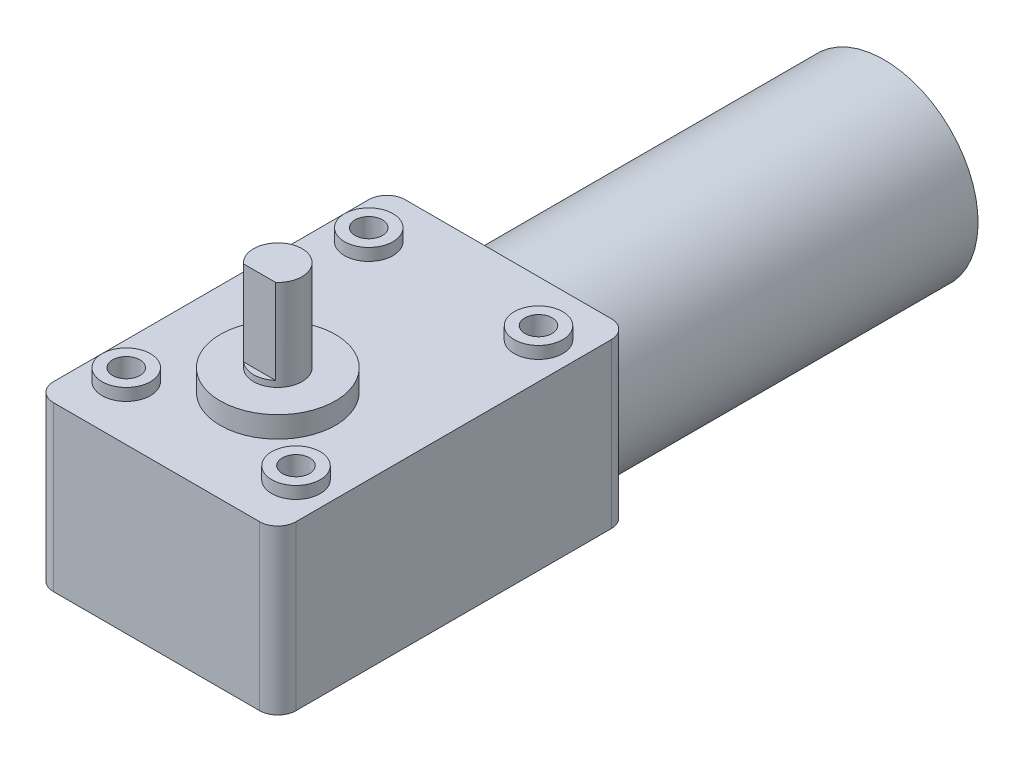
from build123d import *

# Parameters (mm, degrees)
BOSS_EXTRUDE2_DEPTH      = 27
SKETCH2_R                = 4
BOSS_EXTRUDE3_DEPTH      = 2
SKETCH3_R                = 9.5
BOSS_EXTRUDE4_DEPTH      = 3.5
SKETCH4_R                = 4
BOSS_EXTRUDE5_DEPTH      = 1
BOSS_EXTRUDE6_DEPTH      = 14
M4_CLEARANCE_HOLE1_D     = 4.5
M4_CLEARANCE_HOLE1_DEPTH = 9
M4_CLEARANCE_HOLE1_TIP   = 1.351936393
SKETCH8_R                = 15.5
BOSS_EXTRUDE7_DEPTH      = 62
SKETCH9_R                = 7.5
BOSS_EXTRUDE8_DEPTH      = 2


with BuildPart() as part:
    # Sketch1 → Boss-Extrude2 (new body)
    with BuildSketch(Plane(origin=(0, 0, 0), x_dir=(0, 0, -1), z_dir=(0, 1, 0))):
        with BuildLine():
            Line((3, 0), (55, 0))
            ThreePointArc((55, 0), (57.121320344, 0.878679656), (58, 3))
            Line((58, 3), (58, 37))
            ThreePointArc((58, 37), (57.121320344, 39.121320344), (55, 40))
            Line((55, 40), (3, 40))
            ThreePointArc((3, 40), (0.878679656, 39.121320344), (0, 37))
            Line((0, 37), (0, 3))
            ThreePointArc((0, 3), (0.878679656, 0.878679656), (3, 0))
        make_face()
    extrude(amount=BOSS_EXTRUDE2_DEPTH)

    # Sketch2 → Boss-Extrude3 (add)
    with BuildSketch(Plane(origin=(0, 27, 0), x_dir=(1, 0, 0), z_dir=(0, 1, 0))):
        with Locations((-34, 9)):
            Circle(SKETCH2_R)
        with Locations((-6, 9)):
            Circle(SKETCH2_R)
        with Locations((-6, 49)):
            Circle(SKETCH2_R)
        with Locations((-34, 49)):
            Circle(SKETCH2_R)
    extrude(amount=BOSS_EXTRUDE3_DEPTH)

    # Sketch3 → Boss-Extrude4 (add)
    with BuildSketch(Plane(origin=(0, 27, 0), x_dir=(1, 0, 0), z_dir=(0, 1, 0))):
        with Locations((-20, 20)):
            Circle(SKETCH3_R)
    extrude(amount=BOSS_EXTRUDE4_DEPTH)

    # Sketch4 → Boss-Extrude5 (add)
    with BuildSketch(Plane(origin=(0, 30.5, 0), x_dir=(1, 0, 0), z_dir=(0, 1, 0))):
        with Locations((-20, 20)):
            Circle(SKETCH4_R)
    extrude(amount=BOSS_EXTRUDE5_DEPTH)

    # Sketch5 → Boss-Extrude6 (add)
    with BuildSketch(Plane(origin=(0, 31.5, 0), x_dir=(1, 0, 0), z_dir=(0, 1, 0))):
        with BuildLine():
            Line((-22.645751311, 17), (-17.354248689, 17))
            ThreePointArc((-17.354248689, 17), (-20, 24), (-22.645751311, 17))
        make_face()
    extrude(amount=BOSS_EXTRUDE6_DEPTH)

    # M4 Clearance Hole1
    with Locations(Plane(origin=(0, 29, 0), x_dir=(1, 0, 0), z_dir=(0, 1, 0))):
        with Locations((-34, 9), (-34, 49), (-6, 49), (-6, 9)):
            Hole(M4_CLEARANCE_HOLE1_D / 2, depth=M4_CLEARANCE_HOLE1_DEPTH)
            with Locations((0, 0, -(M4_CLEARANCE_HOLE1_DEPTH + M4_CLEARANCE_HOLE1_TIP / 2))):  # 118° drill point
                Cone(0, M4_CLEARANCE_HOLE1_D / 2, M4_CLEARANCE_HOLE1_TIP, mode=Mode.SUBTRACT)

    # Sketch8 → Boss-Extrude7 (add)
    with BuildSketch(Plane(origin=(0, 0, -58), x_dir=(-1, 0, 0), z_dir=(0, 0, -1))):
        with Locations((20, 9)):
            Circle(SKETCH8_R)
    extrude(amount=BOSS_EXTRUDE7_DEPTH)

    # Sketch9 → Boss-Extrude8 (add)
    with BuildSketch(Plane(origin=(0, 0, -120), x_dir=(-1, 0, 0), z_dir=(0, 0, -1))):
        with Locations((20, 9)):
            Circle(SKETCH9_R)
    extrude(amount=BOSS_EXTRUDE8_DEPTH)


solid = part.part
